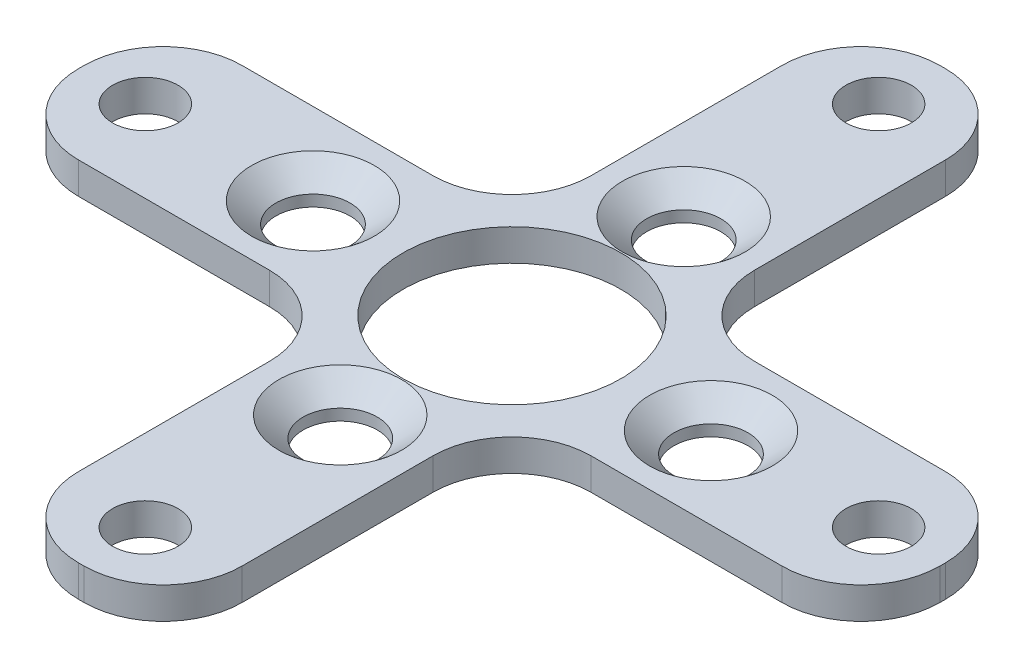
from build123d import *

# Parameters (mm, degrees)
SKETCH1_R                                         = 5.08
SKETCH1_R_2                                       = 1.524
BOSS_EXTRUDE1_DEPTH                               = 1.4732
CSK_FOR_4_FLAT_HEAD_MACHINE_SCREW_100_D           = 3.4544
CSK_FOR_4_FLAT_HEAD_MACHINE_SCREW_100_DEPTH       = 3.44932
CSK_FOR_4_FLAT_HEAD_MACHINE_SCREW_100_CSINK_D     = 5.715
CSK_FOR_4_FLAT_HEAD_MACHINE_SCREW_100_CSINK_ANGLE = 100
CSK_FOR_4_FLAT_HEAD_MACHINE_SCREW_100_TIP         = 1.037806461


with BuildPart() as part:
    # Sketch1 → Boss-Extrude1 (new body)
    with BuildSketch(Plane(origin=(0, 0, 0), x_dir=(1, 0, 0), z_dir=(0, 1, 0))):
        with BuildLine():
            Line((-3.81, 7.493), (-3.81, 16.383))
            ThreePointArc((-3.81, 16.383), (-2.731274275, 18.987274275), (-0.127, 20.066))
            Line((-0.127, 20.066), (0.127, 20.066))
            ThreePointArc((0.127, 20.066), (2.731274275, 18.987274275), (3.81, 16.383))
            Line((3.81, 16.383), (3.81, 7.493))
            ThreePointArc((3.81, 7.493), (4.888725725, 4.888725725), (7.493, 3.81))
            Line((7.493, 3.81), (16.383, 3.81))
            ThreePointArc((16.383, 3.81), (18.987274275, 2.731274275), (20.066, 0.127))
            Line((20.066, 0.127), (20.066, -0.127))
            ThreePointArc((20.066, -0.127), (18.987274275, -2.731274275), (16.383, -3.81))
            Line((16.383, -3.81), (7.493, -3.81))
            ThreePointArc((7.493, -3.81), (4.888725725, -4.888725725), (3.81, -7.493))
            Line((3.81, -7.493), (3.81, -16.383))
            ThreePointArc((3.81, -16.383), (2.731274275, -18.987274275), (0.127, -20.066))
            Line((0.127, -20.066), (-0.127, -20.066))
            ThreePointArc((-0.127, -20.066), (-2.731274275, -18.987274275), (-3.81, -16.383))
            Line((-3.81, -16.383), (-3.81, -7.493))
            ThreePointArc((-3.81, -7.493), (-4.888725725, -4.888725725), (-7.493, -3.81))
            Line((-7.493, -3.81), (-16.383, -3.81))
            ThreePointArc((-16.383, -3.81), (-18.987274275, -2.731274275), (-20.066, -0.127))
            Line((-20.066, -0.127), (-20.066, 0.127))
            ThreePointArc((-20.066, 0.127), (-18.987274275, 2.731274275), (-16.383, 3.81))
            Line((-16.383, 3.81), (-7.493, 3.81))
            ThreePointArc((-7.493, 3.81), (-4.888725725, 4.888725725), (-3.81, 7.493))
        make_face()
        Circle(SKETCH1_R, mode=Mode.SUBTRACT)
        with Locations((0, 17.0815)):
            Circle(SKETCH1_R_2, mode=Mode.SUBTRACT)
        with Locations((17.0815, 0)):
            Circle(SKETCH1_R_2, mode=Mode.SUBTRACT)
        with Locations((-17.0815, 0)):
            Circle(SKETCH1_R_2, mode=Mode.SUBTRACT)
        with Locations((0, -17.0815)):
            Circle(SKETCH1_R_2, mode=Mode.SUBTRACT)
    extrude(amount=BOSS_EXTRUDE1_DEPTH)

    # CSK for #4 Flat Head Machine Screw (100)2
    with Locations(Plane(origin=(0, 1.4732, 0), x_dir=(1, 0, 0), z_dir=(0, 1, 0))):
        with Locations((0, 8.001), (0, -8.001), (9.271, 0), (-9.271, 0)):
            CounterSinkHole(CSK_FOR_4_FLAT_HEAD_MACHINE_SCREW_100_D / 2, CSK_FOR_4_FLAT_HEAD_MACHINE_SCREW_100_CSINK_D / 2, depth=CSK_FOR_4_FLAT_HEAD_MACHINE_SCREW_100_DEPTH, counter_sink_angle=CSK_FOR_4_FLAT_HEAD_MACHINE_SCREW_100_CSINK_ANGLE)
            with Locations((0, 0, -(CSK_FOR_4_FLAT_HEAD_MACHINE_SCREW_100_DEPTH + CSK_FOR_4_FLAT_HEAD_MACHINE_SCREW_100_TIP / 2))):  # 118° drill point
                Cone(0, CSK_FOR_4_FLAT_HEAD_MACHINE_SCREW_100_D / 2, CSK_FOR_4_FLAT_HEAD_MACHINE_SCREW_100_TIP, mode=Mode.SUBTRACT)


solid = part.part
